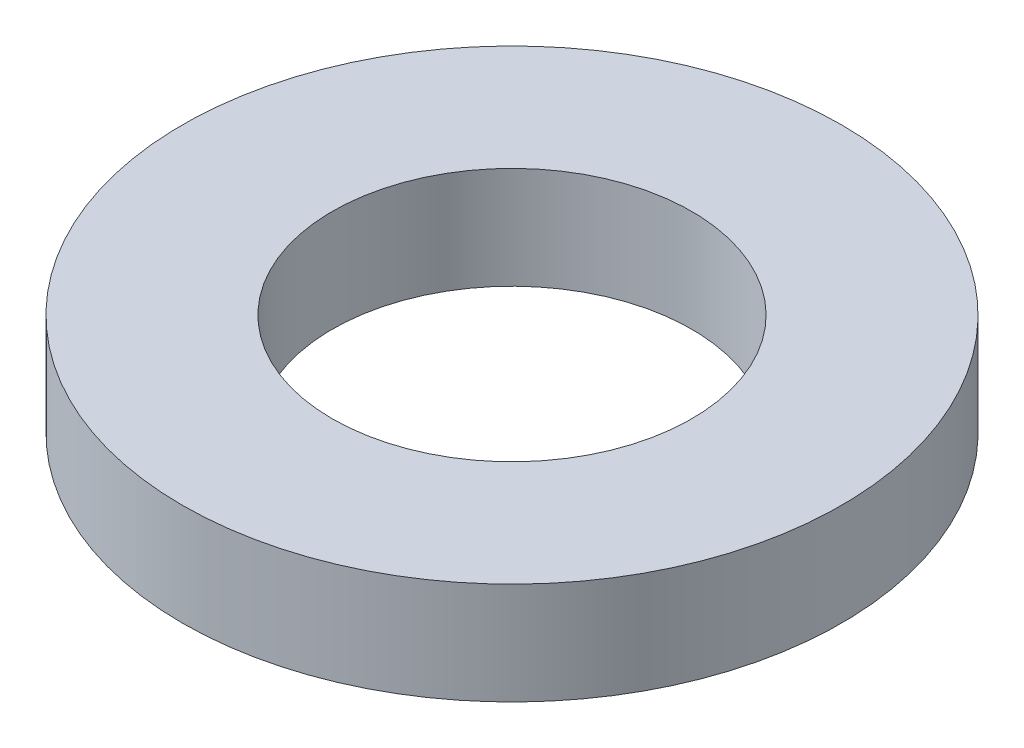
from build123d import *

# Parameters (mm, degrees)
SKETCH1_R           = 11.6459
SKETCH1_R_2         = 6.35
BOSS_EXTRUDE1_DEPTH = 1.8034


with BuildPart() as part:
    # Sketch1 → Boss-Extrude1 (new body, symmetric)
    with BuildSketch(Plane(origin=(0, 0, 0), x_dir=(1, 0, 0), z_dir=(0, 1, 0))):
        Circle(SKETCH1_R)
        Circle(SKETCH1_R_2, mode=Mode.SUBTRACT)
    extrude(amount=BOSS_EXTRUDE1_DEPTH, both=True)


solid = part.part
